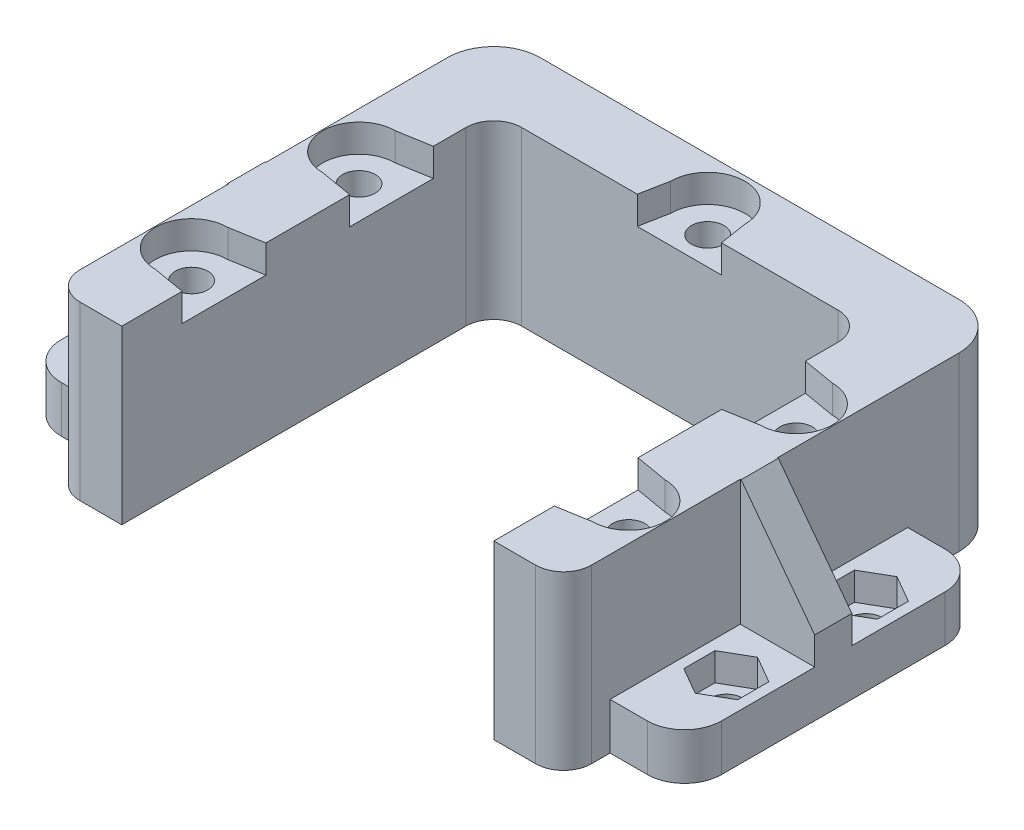
from build123d import *

# Parameters (mm, degrees)
BOSS_EXTRUDE1_DEPTH       = 18.5
SKETCH2_R                 = 1.75
CUT_EXTRUDE1_DEPTH        = 15.5
CUT_EXTRUDE2_DEPTH        = 3
SKETCH4_W                 = 32
SKETCH4_H                 = 5
BOSS_EXTRUDE2_DEPTH       = 8
FILLET1_R                 = 4
SKETCH5_R                 = 1.75
CUT_EXTRUDE3_DEPTH        = 6
SKETCH6_W                 = 4
SKETCH6_H                 = 13.5
BOSS_EXTRUDE3_DEPTH       = 8
CHAMFER1_SIZE             = 10.5
CHAMFER1_SIZE2            = 7.912317526
CUT_EXTRUDE4_DEPTH        = 3
FILLET1_OF_MIRROR1_R      = 4
CHAMFER1_OF_MIRROR1_SIZE2 = 7.912317526
CHAMFER1_OF_MIRROR1_SIZE  = 10.5
CUT_EXTRUDE7_DEPTH        = 3


with BuildPart() as part:
    # Sketch1 → Boss-Extrude1 (new body)
    with BuildSketch(Plane(origin=(0, 0, 0), x_dir=(1, 0, 0), z_dir=(0, 1, 0))):
        with BuildLine():
            Line((-20, -20), (-24.5, -20))
            ThreePointArc((-24.5, -20), (-26.621320344, -19.121320344), (-27.5, -17))
            Line((-27.5, -17), (-27.5, 22.5))
            ThreePointArc((-27.5, 22.5), (-26.035533906, 26.035533906), (-22.5, 27.5))
            Line((-22.5, 27.5), (22.5, 27.5))
            ThreePointArc((22.5, 27.5), (26.035533906, 26.035533906), (27.5, 22.5))
            Line((27.5, 22.5), (27.5, -17))
            ThreePointArc((27.5, -17), (26.621320344, -19.121320344), (24.5, -20))
            Line((24.5, -20), (20, -20))
            Line((20, -20), (20, 17))
            ThreePointArc((20, 17), (19.121320344, 19.121320344), (17, 20))
            Line((17, 20), (-17, 20))
            ThreePointArc((-17, 20), (-19.121320344, 19.121320344), (-20, 17))
            Line((-20, 17), (-20, -20))
        make_face()
    extrude(amount=BOSS_EXTRUDE1_DEPTH)

    # Sketch2 → Cut-Extrude1 (cut)
    with BuildSketch(Plane(origin=(0, 18.5, 0), x_dir=(1, 0, 0), z_dir=(0, 1, 0))):
        with Locations((-23.5, -9)):
            Circle(SKETCH2_R)
        with Locations((23.5, -9)):
            Circle(SKETCH2_R)
        with Locations((0, 23)):
            Circle(SKETCH2_R)
        with Locations((-23.5, 9)):
            Circle(SKETCH2_R)
        with Locations((23.5, 9)):
            Circle(SKETCH2_R)
    extrude(amount=-CUT_EXTRUDE1_DEPTH, mode=Mode.SUBTRACT)

    # Sketch3 → Cut-Extrude2 (cut)
    with BuildSketch(Plane.XZ):
        Polygon((-20.6, 7.325684219), (-20.6, 10.674315781), (-23.5, 12.348631561), (-26.4, 10.674315781), (-26.4, 7.325684219), (-23.5, 5.651368439), align=None)
        Polygon((23.4996681, 5.651368455), (26.399834036, 7.325396794), (26.400165936, 10.674028339), (23.5003319, 12.348631545), (20.600165964, 10.674603206), (20.599834064, 7.325971661), align=None)
        Polygon((3.348631561, -23), (1.674315781, -20.1), (-1.674315781, -20.1), (-3.348631561, -23), (-1.674315781, -25.9), (1.674315781, -25.9), align=None)
        Polygon((-23.4996681, -5.651368455), (-26.399834036, -7.325396794), (-26.400165936, -10.674028339), (-23.5003319, -12.348631545), (-20.600165964, -10.674603206), (-20.599834064, -7.325971661), align=None)
        Polygon((23.4996681, -5.651368455), (20.599834064, -7.325971661), (20.600165964, -10.674603206), (23.5003319, -12.348631545), (26.400165936, -10.674028339), (26.399834036, -7.325396794), align=None)
    extrude(amount=-CUT_EXTRUDE2_DEPTH, mode=Mode.SUBTRACT)

    # Sketch4 → Boss-Extrude2 (add)
    with BuildSketch(Plane.ZY.offset(27.5)):
        with Locations((-1, 2.5)):
            Rectangle(SKETCH4_W, SKETCH4_H)
    boss_extrude2 = extrude(amount=BOSS_EXTRUDE2_DEPTH)

    # Fillet1
    fillet1_edges = [part.edges().sort_by_distance(p)[0] for p in [
        (-35.5, 2.5, -17),
        (-35.5, 2.5, 15),
    ]]
    fillet(fillet1_edges, radius=FILLET1_R)

    # Sketch5 → Cut-Extrude3 (cut)
    with BuildSketch(Plane(origin=(0, 5, 0), x_dir=(1, 0, 0), z_dir=(0, 1, 0))):
        with Locations((-31.5, 8.5)):
            Circle(SKETCH5_R)
        with Locations((-31.5, -6.5)):
            Circle(SKETCH5_R)
    cut_extrude3 = extrude(amount=-CUT_EXTRUDE3_DEPTH, mode=Mode.SUBTRACT)

    # Sketch6 → Boss-Extrude3 (add)
    with BuildSketch(Plane.ZY.offset(27.5)):
        with Locations((-1, 11.75)):
            Rectangle(SKETCH6_W, SKETCH6_H)
    boss_extrude3 = extrude(amount=BOSS_EXTRUDE3_DEPTH)

    # Chamfer1
    chamfer1_edges = [part.edges().sort_by_distance(p)[0] for p in [
        (-35.5, 18.5, -1),
    ]]
    chamfer1_side = [part.faces().sort_by_distance(p)[0] for p in [
        (-35.5, 5.370689655, -1),
    ]]
    chamfer(chamfer1_edges, length=CHAMFER1_SIZE, length2=CHAMFER1_SIZE2, reference=chamfer1_side[0])

    # Sketch7 → Cut-Extrude4 (cut)
    with BuildSketch(Plane(origin=(0, 5, 0), x_dir=(1, 0, 0), z_dir=(0, 1, 0))):
        Polygon((-31.5, 11.848631561), (-34.4, 10.174315781), (-34.4, 6.825684219), (-31.5, 5.151368439), (-28.6, 6.825684219), (-28.6, 10.174315781), align=None)
        Polygon((-31.5, -3.151368439), (-34.4, -4.825684219), (-34.4, -8.174315781), (-31.5, -9.848631561), (-28.6, -8.174315781), (-28.6, -4.825684219), align=None)
    cut_extrude4 = extrude(amount=-CUT_EXTRUDE4_DEPTH, mode=Mode.SUBTRACT)

    # Mirror1: Boss-Extrude2, Cut-Extrude3, Boss-Extrude3, Cut-Extrude4 across plane
    add(boss_extrude2.mirror(Plane(origin=(0, 0, 0), x_dir=(0, 0, 1), z_dir=(1, 0, 0))))
    add(cut_extrude3.mirror(Plane(origin=(0, 0, 0), x_dir=(0, 0, 1), z_dir=(1, 0, 0))), mode=Mode.SUBTRACT)
    add(boss_extrude3.mirror(Plane(origin=(0, 0, 0), x_dir=(0, 0, 1), z_dir=(1, 0, 0))))
    add(cut_extrude4.mirror(Plane(origin=(0, 0, 0), x_dir=(0, 0, 1), z_dir=(1, 0, 0))), mode=Mode.SUBTRACT)

    # Fillet1 of Mirror1
    fillet1_of_mirror1_edges = [part.edges().sort_by_distance(p)[0] for p in [
        (35.5, 2.5, -17),
        (35.5, 2.5, 15),
    ]]
    fillet(fillet1_of_mirror1_edges, radius=FILLET1_OF_MIRROR1_R)

    # Chamfer1 of Mirror1
    chamfer1_of_mirror1_edges = [part.edges().sort_by_distance(p)[0] for p in [
        (35.5, 18.5, -1),
    ]]
    chamfer(chamfer1_of_mirror1_edges, length=CHAMFER1_OF_MIRROR1_SIZE, length2=CHAMFER1_OF_MIRROR1_SIZE2)

    # Sketch8 → Cut-Extrude7 (cut)
    with BuildSketch(Plane(origin=(0, 18.5, 0), x_dir=(1, 0, 0), z_dir=(0, 1, 0))):
        with BuildLine():
            Line((-4, 23), (-4.57455059, 20))
            Line((-4.57455059, 20), (4.478329848, 20))
            Line((4.478329848, 20), (4, 23))
            ThreePointArc((4, 23), (0, 27), (-4, 23))
        make_face()
        with BuildLine():
            Line((23.5, 12.9), (20, 13.5))
            Line((20, 13.5), (20, 4.5))
            Line((20, 4.5), (23.5, 5.1))
            ThreePointArc((23.5, 5.1), (27.4, 9), (23.5, 12.9))
        make_face()
        with BuildLine():
            Line((23.5, -5.1), (20, -4.5))
            Line((20, -4.5), (20, -13.5))
            Line((20, -13.5), (23.5, -12.9))
            ThreePointArc((23.5, -12.9), (27.4, -9), (23.5, -5.1))
        make_face()
        with BuildLine():
            Line((-23.5, -12.9), (-20, -13.5))
            Line((-20, -13.5), (-20, -4.5))
            Line((-20, -4.5), (-23.5, -5.1))
            ThreePointArc((-23.5, -5.1), (-27.4, -9), (-23.5, -12.9))
        make_face()
        with BuildLine():
            Line((-23.5, 12.9), (-20, 13.5))
            Line((-20, 13.5), (-20, 4.5))
            Line((-20, 4.5), (-23.5, 5.1))
            ThreePointArc((-23.5, 5.1), (-27.4, 9), (-23.5, 12.9))
        make_face()
    extrude(amount=-CUT_EXTRUDE7_DEPTH, mode=Mode.SUBTRACT)


solid = part.part
